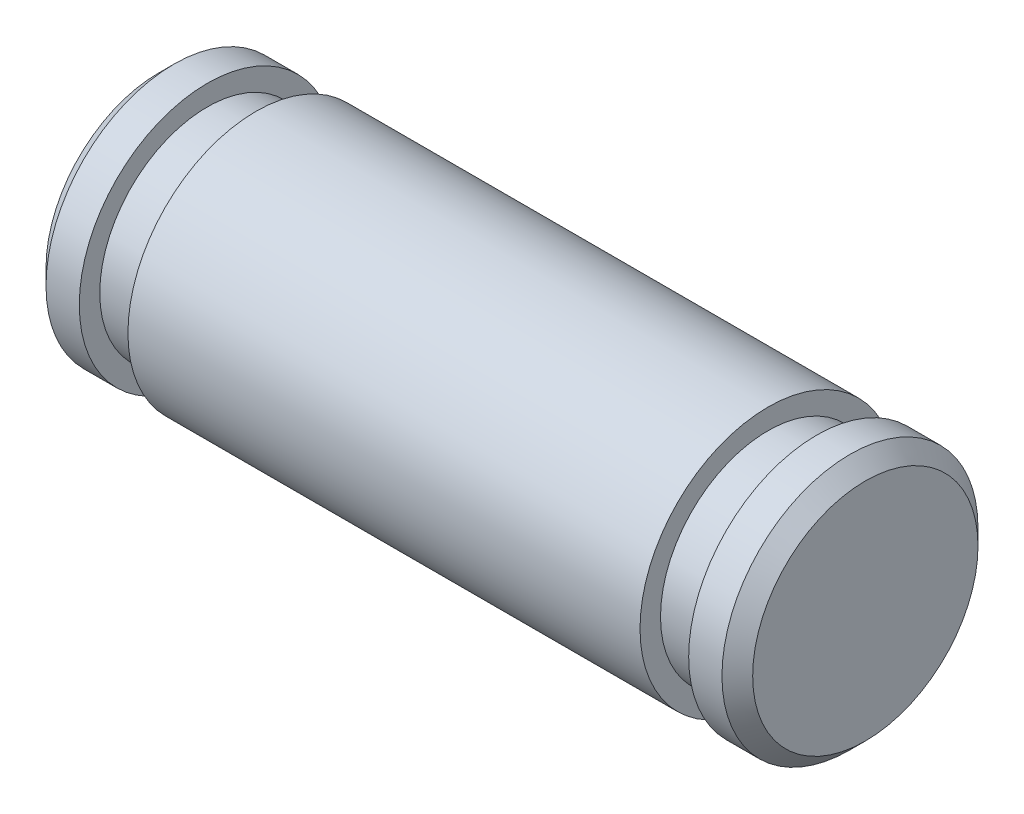
from build123d import *


with BuildPart() as part:
    # Sketch1 → Revolve1 (revolve)
    with BuildSketch(Plane.XY):
        Polygon((-8.763, 0), (-8.763, 2.794), (-8.382, 3.175), (-7.5565, 3.175), (-7.5565, 2.667), (-6.35, 2.667), (-6.35, 3.175), (6.35, 3.175), (6.35, 2.667), (7.5565, 2.667), (7.5565, 3.175), (8.382, 3.175), (8.763, 2.794), (8.763, 0), align=None)
    revolve(axis=Axis((8.763, 0, 0), (-1, 0, 0)))


solid = part.part
